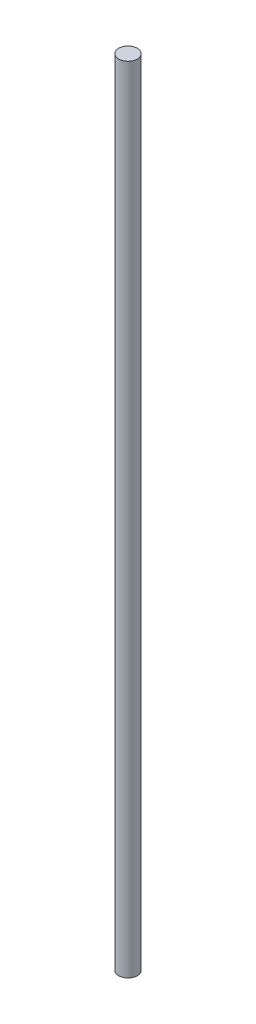
from build123d import *

# Parameters (mm, degrees)
SKETCH1_R           = 82.5
BOSS_EXTRUDE1_DEPTH = 7000


with BuildPart() as part:
    # Sketch1 → Boss-Extrude1 (new body)
    with BuildSketch(Plane(origin=(0, 0, 0), x_dir=(1, 0, 0), z_dir=(0, 1, 0))):
        Circle(SKETCH1_R)
    extrude(amount=BOSS_EXTRUDE1_DEPTH)


solid = part.part
